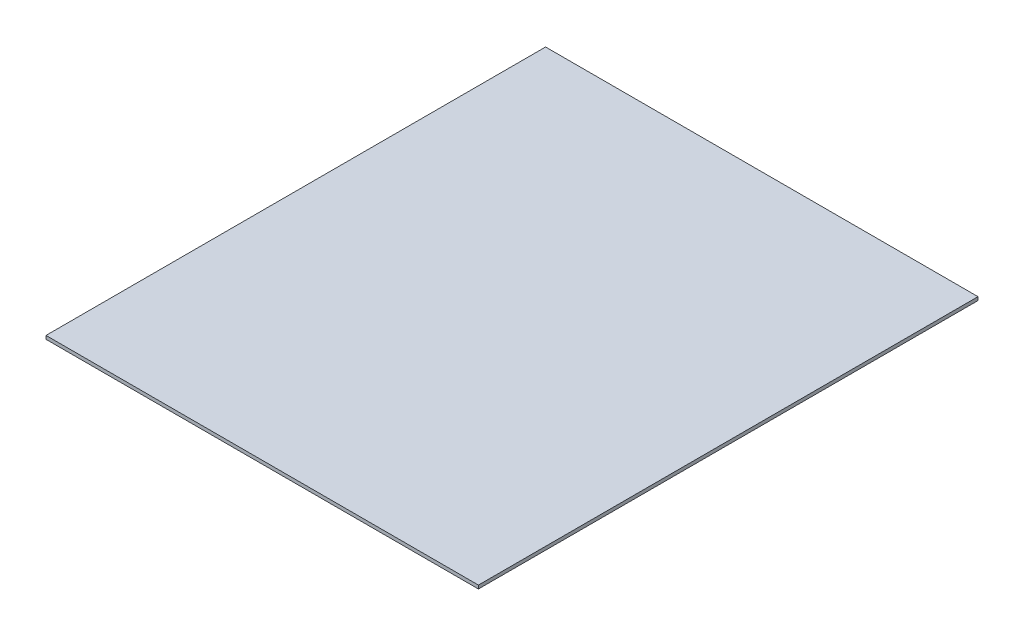
from build123d import *

# Parameters (mm, degrees)
SKETCH1_W           = 380
SKETCH1_H           = 439
BOSS_EXTRUDE1_DEPTH = 3


with BuildPart() as part:
    # Sketch1 → Boss-Extrude1 (new body)
    with BuildSketch(Plane(origin=(0, 0, 0), x_dir=(1, 0, 0), z_dir=(0, 1, 0))):
        Rectangle(SKETCH1_W, SKETCH1_H)
    extrude(amount=BOSS_EXTRUDE1_DEPTH)


solid = part.part
